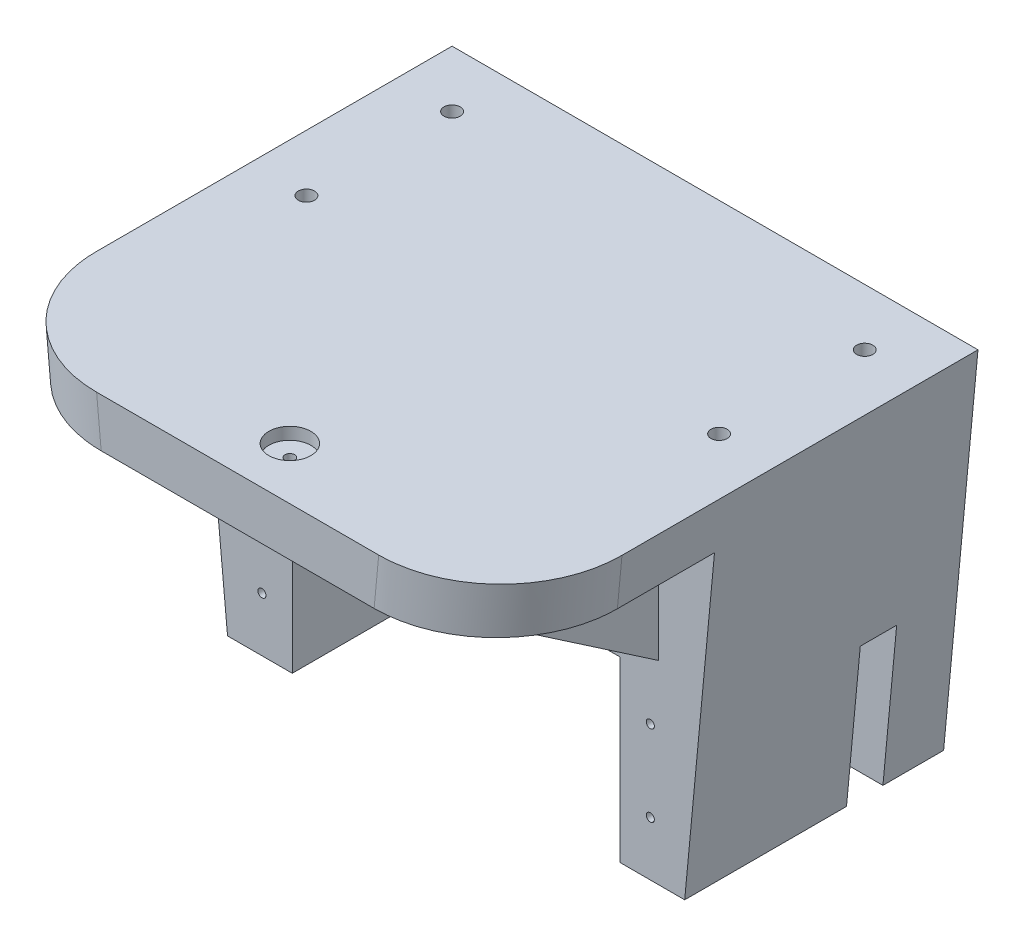
from build123d import *

# Parameters (mm, degrees)
RESSALTO_EXTRUS_O1_DEPTH = 30
ESBO_O3_W                = 4.5
ESBO_O3_H                = 18
CORTE_EXTRUS_O2_DEPTH    = 28.5
RESSALTO_EXTRUS_O2_DEPTH = 2
ESBO_O5_R                = 0.5
CORTE_EXTRUS_O3_DEPTH    = 10
ESBO_O6_R                = 1
CORTE_EXTRUS_O4_DEPTH    = 10
RESSALTO_EXTRUS_O3_DEPTH = 27
RESSALTO_EXTRUS_O4_DEPTH = 5
FILETE1_R                = 15
ESBO_O11_R               = 2.6
CORTE_EXTRUS_O5_DEPTH    = 1.5
ESBO_O12_R               = 0.6
CORTE_EXTRUS_O6_DEPTH    = 4.5
CHANFRO1_SIZE            = 0.5


with BuildPart() as part:
    # Esboço1 → Ressalto-extrusão1 (new body)
    with BuildSketch(Plane.XY):
        Polygon((-32.5, 31.319481807), (32.5, 31.319481807), (28.25, -13.680518193), (20.25, -13.680518193), (20.25, 8.319481807), (-20.25, 8.319481807), (-20.25, -13.680518193), (-28.25, -13.680518193), align=None)
    extrude(amount=RESSALTO_EXTRUS_O1_DEPTH)

    # Esboço3 → Corte-extrusão2 (cut)
    with BuildSketch(Plane(origin=(40, 0, 0), x_dir=(0, 0, -1), z_dir=(1, 0, 0))):
        with Locations((-7.75, -4.680518193)):
            Rectangle(ESBO_O3_W, ESBO_O3_H)
    extrude(amount=-CORTE_EXTRUS_O2_DEPTH, mode=Mode.SUBTRACT)

    # Esboço4 → Ressalto-extrusão2 (add)
    with BuildSketch(Plane(origin=(0, 0, 0), x_dir=(-1, 0, 0), z_dir=(0, 0, -1))):
        Polygon((-32.5, 31.319481807), (32.5, 31.319481807), (28.25, -13.680518193), (20.25, -13.680518193), (-20.25, -13.680518193), (-28.25, -13.680518193), align=None)
    extrude(amount=RESSALTO_EXTRUS_O2_DEPTH)

    # Esboço5 → Corte-extrusão3 (cut)
    with BuildSketch(Plane.XY.offset(30)):
        with Locations((-24, 3.019481807)):
            Circle(ESBO_O5_R)
        with Locations((24, 3.019481807)):
            Circle(ESBO_O5_R)
        with Locations((-24, -6.980518193)):
            Circle(ESBO_O5_R)
        with Locations((24, -6.980518193)):
            Circle(ESBO_O5_R)
    extrude(amount=-CORTE_EXTRUS_O3_DEPTH, mode=Mode.SUBTRACT)

    # Esboço6 → Corte-extrusão4 (cut)
    with BuildSketch(Plane(origin=(0, 31.319481807, 0), x_dir=(1, 0, 0), z_dir=(0, 1, 0))):
        with Locations((-25.5, -5)):
            Circle(ESBO_O6_R)
        with Locations((-25.5, -23)):
            Circle(ESBO_O6_R)
        with Locations((25.5, -5)):
            Circle(ESBO_O6_R)
        with Locations((25.5, -23)):
            Circle(ESBO_O6_R)
    extrude(amount=-CORTE_EXTRUS_O4_DEPTH, mode=Mode.SUBTRACT)

    # Esboço7 → Ressalto-extrusão3 (add)
    with BuildSketch(Plane.XY.offset(30)):
        Polygon((-32.5, 31.319481807), (32.5, 31.319481807), (31.933333333, 25.319481807), (-31.933333333, 25.319481807), align=None)
    extrude(amount=RESSALTO_EXTRUS_O3_DEPTH)

    # Esboço10 → Ressalto-extrusão4 (add)
    with BuildSketch(Plane(origin=(20, 0, 0), x_dir=(0, 0, -1), z_dir=(1, 0, 0))):
        Polygon((-30, 25.319481807), (-30, 10.319481807), (-52, 25.319481807), align=None)
    ressalto_extrus_o4 = extrude(amount=RESSALTO_EXTRUS_O4_DEPTH)

    # Espelhar1: Ressalto-extrusão4 across plane
    add(ressalto_extrus_o4.mirror(Plane(origin=(0, 0, 0), x_dir=(0, 0, 1), z_dir=(1, 0, 0))))

    # Filete1
    filete1_edges = [part.edges().sort_by_distance(p)[0] for p in [
        (-32.216666667, 28.319481807, 57),
        (32.216666667, 28.319481807, 57),
    ]]
    fillet(filete1_edges, radius=FILETE1_R)

    # Esboço11 → Corte-extrusão5 (cut)
    with BuildSketch(Plane(origin=(0, 31.319481807, 0), x_dir=(1, 0, 0), z_dir=(0, 1, 0))):
        with Locations((0, -50.55)):
            Circle(ESBO_O11_R)
    extrude(amount=-CORTE_EXTRUS_O5_DEPTH, mode=Mode.SUBTRACT)

    # Esboço12 → Corte-extrusão6 (cut)
    with BuildSketch(Plane(origin=(0, 29.819481807, 0), x_dir=(1, 0, 0), z_dir=(0, 1, 0))):
        with Locations((0, -50.55)):
            Circle(ESBO_O12_R)
    extrude(amount=-CORTE_EXTRUS_O6_DEPTH, mode=Mode.SUBTRACT)

    # Chanfro1
    chanfro1_edges = [part.edges().sort_by_distance(p)[0] for p in [
        (-0.6, 25.319481807, 50.55),
    ]]
    chamfer(chanfro1_edges, length=CHANFRO1_SIZE)


solid = part.part
